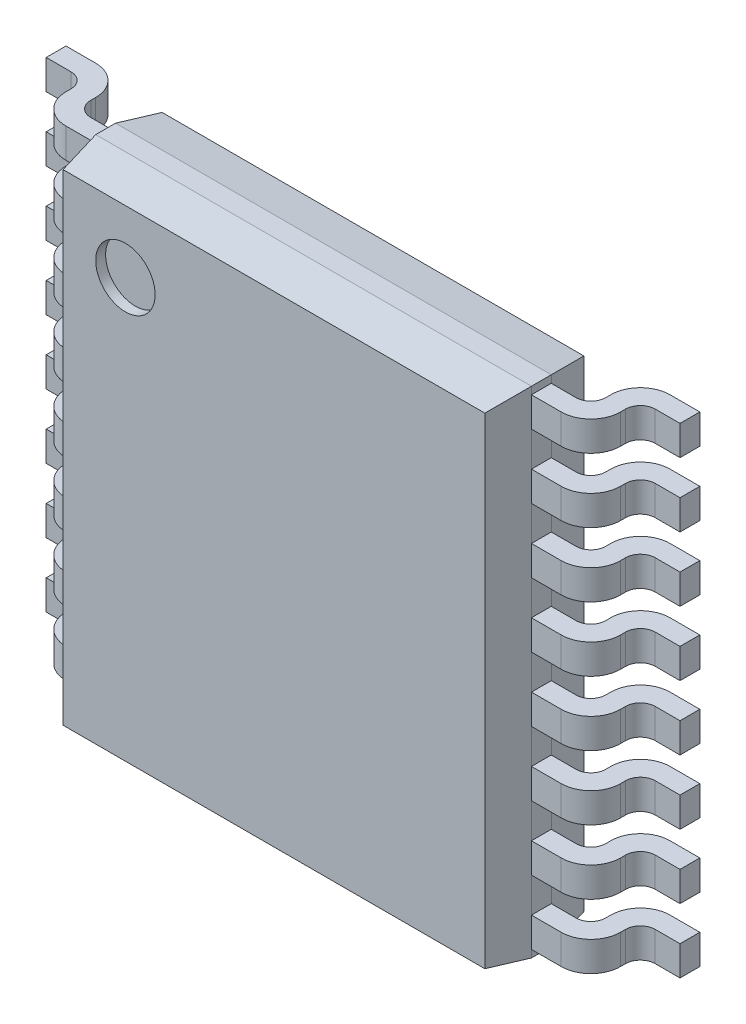
from build123d import *

# Parameters (mm, degrees)
SKETCH_1_W             = 4.4
SKETCH_1_H             = 5
EXTRUDE_1_DEPTH        = 1
CHAMFER_1_SIZE         = 0.4
CHAMFER_1_SIZE2        = 0.070530792
CHAMFER_1_PART_2_SIZE  = 0.4
CHAMFER_1_PART_2_SIZE2 = 0.070530792
CHAMFER_1_PART_3_SIZE  = 0.4
CHAMFER_1_PART_3_SIZE2 = 0.070530792
CHAMFER_1_PART_4_SIZE  = 0.4
CHAMFER_1_PART_4_SIZE2 = 0.070530792
EXTRUDE_2_DEPTH        = 0.15
PATTERN_LINEAR_1_COUNT = 8
PATTERN_LINEAR_1_PITCH = 0.65
SKETCH_4_R             = 0.3
CUT_EXTRUDE_1_DEPTH    = 0.1


with BuildPart() as part:
    # Эскиз1 → Бобышка-Вытянуть1 (new body)
    with BuildSketch(Plane.XY.offset(0.1)):
        Rectangle(SKETCH_1_W, SKETCH_1_H)
    extrude(amount=EXTRUDE_1_DEPTH)

    # Фаска1
    chamfer_1_edges = [part.edges().sort_by_distance(p)[0] for p in [
        (2.2, 0, 1.1),
        (2.2, 0, 0.1),
    ]]
    chamfer_1_side = [part.faces().sort_by_distance(p)[0] for p in [
        (2.2, 0, 0.6),
    ]]
    chamfer(chamfer_1_edges, length=CHAMFER_1_SIZE, length2=CHAMFER_1_SIZE2, reference=chamfer_1_side[0])

    # Фаска1 part 2
    chamfer_1_part_2_edges = [part.edges().sort_by_distance(p)[0] for p in [
        (0, 2.5, 1.1),
        (0, 2.5, 0.1),
    ]]
    chamfer_1_part_2_side = [part.faces().sort_by_distance(p)[0] for p in [
        (0, 2.5, 0.6),
    ]]
    chamfer(chamfer_1_part_2_edges, length=CHAMFER_1_PART_2_SIZE, length2=CHAMFER_1_PART_2_SIZE2, reference=chamfer_1_part_2_side[0])

    # Фаска1 part 3
    chamfer_1_part_3_edges = [part.edges().sort_by_distance(p)[0] for p in [
        (-2.2, 0, 1.1),
        (-2.2, 0, 0.1),
    ]]
    chamfer_1_part_3_side = [part.faces().sort_by_distance(p)[0] for p in [
        (-2.2, 0, 0.6),
    ]]
    chamfer(chamfer_1_part_3_edges, length=CHAMFER_1_PART_3_SIZE, length2=CHAMFER_1_PART_3_SIZE2, reference=chamfer_1_part_3_side[0])

    # Фаска1 part 4
    chamfer_1_part_4_edges = [part.edges().sort_by_distance(p)[0] for p in [
        (0, -2.5, 0.1),
        (0, -2.5, 1.1),
    ]]
    chamfer_1_part_4_side = [part.faces().sort_by_distance(p)[0] for p in [
        (0, -2.5, 0.6),
    ]]
    chamfer(chamfer_1_part_4_edges, length=CHAMFER_1_PART_4_SIZE, length2=CHAMFER_1_PART_4_SIZE2, reference=chamfer_1_part_4_side[0])

    # Эскиз3 → Бобышка-Вытянуть2 (add, symmetric)
    with BuildSketch(Plane(origin=(0, 2.275, 0), x_dir=(-1, 0, 0), z_dir=(0, 1, 0))):
        with BuildLine():
            Line((-2.2, 0.5), (-2.2, 0.7))
            Line((-2.2, 0.7), (-2.5, 0.7))
            ThreePointArc((-2.5, 0.7), (-2.712132034, 0.612132034), (-2.8, 0.4))
            Line((-2.8, 0.4), (-2.8, 0.35))
            ThreePointArc((-2.8, 0.35), (-2.843933983, 0.243933983), (-2.95, 0.2))
            Line((-2.95, 0.2), (-3.2, 0.2))
            Line((-3.2, 0.2), (-3.2, 0))
            Line((-3.2, 0), (-2.9, 0))
            ThreePointArc((-2.9, 0), (-2.687867966, 0.087867966), (-2.6, 0.3))
            Line((-2.6, 0.3), (-2.6, 0.35))
            ThreePointArc((-2.6, 0.35), (-2.556066017, 0.456066017), (-2.45, 0.5))
            Line((-2.45, 0.5), (-2.2, 0.5))
        make_face()
        with BuildLine():
            Line((2.8, 0.4), (2.8, 0.35))
            ThreePointArc((2.8, 0.35), (2.843933983, 0.243933983), (2.95, 0.2))
            Line((2.95, 0.2), (3.2, 0.2))
            Line((3.2, 0.2), (3.2, 0))
            Line((3.2, 0), (2.9, 0))
            ThreePointArc((2.9, 0), (2.687867966, 0.087867966), (2.6, 0.3))
            Line((2.6, 0.3), (2.6, 0.35))
            ThreePointArc((2.6, 0.35), (2.556066017, 0.456066017), (2.45, 0.5))
            Line((2.45, 0.5), (2.2, 0.5))
            Line((2.2, 0.5), (2.2, 0.7))
            Line((2.2, 0.7), (2.5, 0.7))
            ThreePointArc((2.5, 0.7), (2.712132034, 0.612132034), (2.8, 0.4))
        make_face()
    extrude_2 = extrude(amount=EXTRUDE_2_DEPTH, both=True)

    # Линейный массив1: Бобышка-Вытянуть2 ×8
    with Locations(*[(0, -i * PATTERN_LINEAR_1_PITCH, 0) for i in range(1, PATTERN_LINEAR_1_COUNT)]):
        add(extrude_2)

    # Эскиз4 → Вырез-Вытянуть1 (cut)
    with BuildSketch(Plane.XY.offset(1.1)):
        with Locations((-1.5, 1.8)):
            Circle(SKETCH_4_R)
    extrude(amount=-CUT_EXTRUDE_1_DEPTH, mode=Mode.SUBTRACT)


solid = part.part
